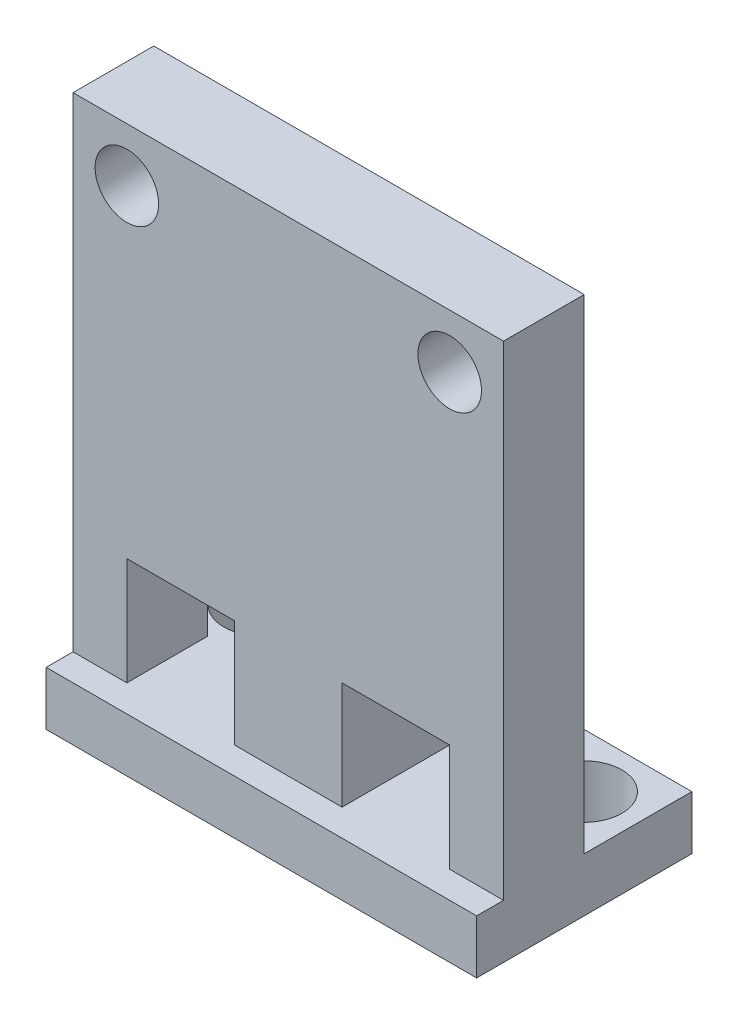
from build123d import *

# Parameters (mm, degrees)
SKETCH1_W               = 20.32
SKETCH1_H               = 25.4
BOSS_EXTRUDE1_DEPTH     = 5.08
ELECTRONICS_HOLES_REACH = 7.08
SKETCH2_R               = 1.499997
SKETCH3_W               = 20.32
SKETCH3_H               = 10.16
BOSS_EXTRUDE2_DEPTH     = 2.54
SKETCH4_W               = 20.32
SKETCH4_H               = 22.86
CUT_EXTRUDE2_DEPTH      = 1.27
SKETCH5_R               = 1.778
PLACEMENT_HOLES_DEPTH   = 2.54
SKETCH6_W               = 15.24
SKETCH6_H               = 5.08
CUT_EXTRUDE4_DEPTH      = 9.89
BOSS_EXTRUDE3_DEPTH     = 2.54


with BuildPart() as part:
    # Sketch1 → Boss-Extrude1 (new body)
    with BuildSketch(Plane.XY):
        with Locations((10.16, 12.7)):
            Rectangle(SKETCH1_W, SKETCH1_H)
    extrude(amount=BOSS_EXTRUDE1_DEPTH)

    # Sketch2 → Electronics Holes (cut, up to next)
    with BuildSketch(Plane.XY.offset(5.08), mode=Mode.PRIVATE) as electronics_holes_sk1:
        with Locations((2.54, 22.86)):
            Circle(SKETCH2_R)
    electronics_holes_tool1 = extrude(electronics_holes_sk1.sketch, amount=-ELECTRONICS_HOLES_REACH, mode=Mode.PRIVATE) & part.part
    add(electronics_holes_tool1.solids().sort_by_distance((2.54, 22.86, 5.08))[0], mode=Mode.SUBTRACT)
    # Sketch2 → Electronics Holes (cut, up to next)
    with BuildSketch(Plane.XY.offset(5.08), mode=Mode.PRIVATE) as electronics_holes_sk2:
        with Locations((17.78, 22.86)):
            Circle(SKETCH2_R)
    electronics_holes_tool2 = extrude(electronics_holes_sk2.sketch, amount=-ELECTRONICS_HOLES_REACH, mode=Mode.PRIVATE) & part.part
    add(electronics_holes_tool2.solids().sort_by_distance((17.78, 22.86, 5.08))[0], mode=Mode.SUBTRACT)

    # Sketch3 → Boss-Extrude2 (add)
    with BuildSketch(Plane.XZ):
        with Locations((10.16, 0)):
            Rectangle(SKETCH3_W, SKETCH3_H)
    extrude(amount=-BOSS_EXTRUDE2_DEPTH)

    # Sketch4 → Cut-Extrude2 (cut)
    with BuildSketch(Plane.XY.offset(5.08)):
        with Locations((10.16, 13.97)):
            Rectangle(SKETCH4_W, SKETCH4_H)
    extrude(amount=-CUT_EXTRUDE2_DEPTH, mode=Mode.SUBTRACT)

    # Sketch5 → Placement Holes (cut)
    with BuildSketch(Plane(origin=(0, 2.54, 0), x_dir=(1, 0, 0), z_dir=(0, 1, 0))):
        with Locations((17.78, 2.54)):
            Circle(SKETCH5_R)
        with Locations((2.54, 2.54)):
            Circle(SKETCH5_R)
    extrude(amount=-PLACEMENT_HOLES_DEPTH, mode=Mode.SUBTRACT)

    # Sketch6 → Cut-Extrude4 (cut, through all)
    with BuildSketch(Plane.XY.offset(3.81)):
        with Locations((10.16, 5.08)):
            Rectangle(SKETCH6_W, SKETCH6_H)
    extrude(amount=-CUT_EXTRUDE4_DEPTH, mode=Mode.SUBTRACT)

    # Sketch7 → Boss-Extrude3 (add)
    with BuildSketch(Plane.ZY.offset(-10.16)):
        Polygon((0, 25.4), (-5.08, 2.54), (3.81, 2.54), (3.81, 25.4), align=None)
    boss_extrude3 = extrude(amount=BOSS_EXTRUDE3_DEPTH)

    # Mirror1: Boss-Extrude3 across plane
    add(boss_extrude3.mirror(Plane.ZY.offset(-10.16)))


solid = part.part
